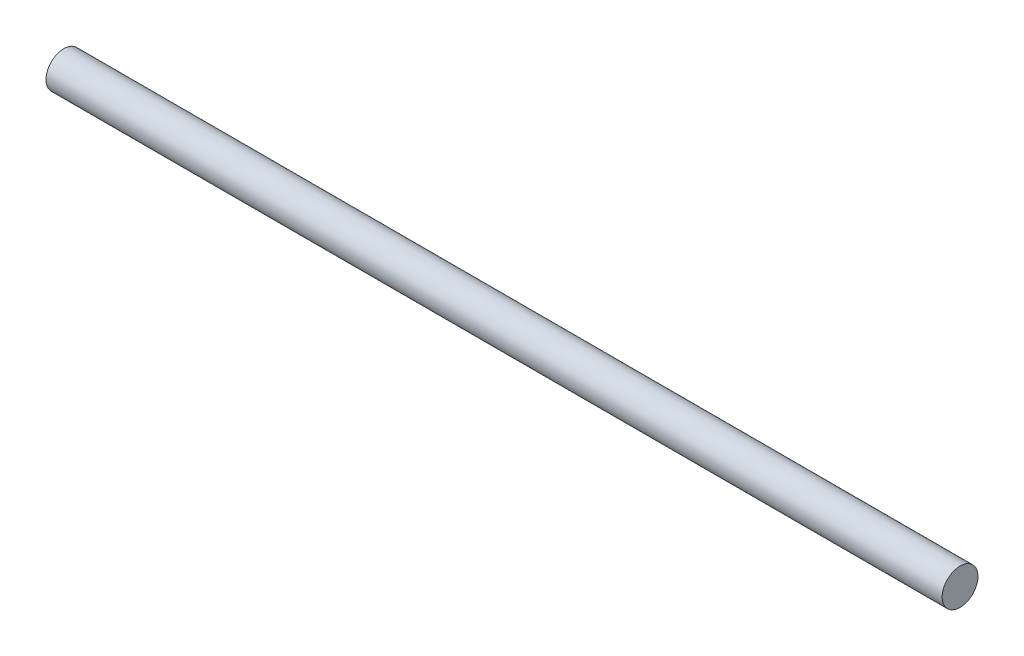
from build123d import *

# Parameters (mm, degrees)
SKETCH1_R           = 5
BOSS_EXTRUDE1_DEPTH = 250


with BuildPart() as part:
    # Sketch1 → Boss-Extrude1 (new body)
    with BuildSketch(Plane(origin=(0, 0, 0), x_dir=(0, 0, -1), z_dir=(1, 0, 0))):
        Circle(SKETCH1_R)
    extrude(amount=BOSS_EXTRUDE1_DEPTH)


solid = part.part
